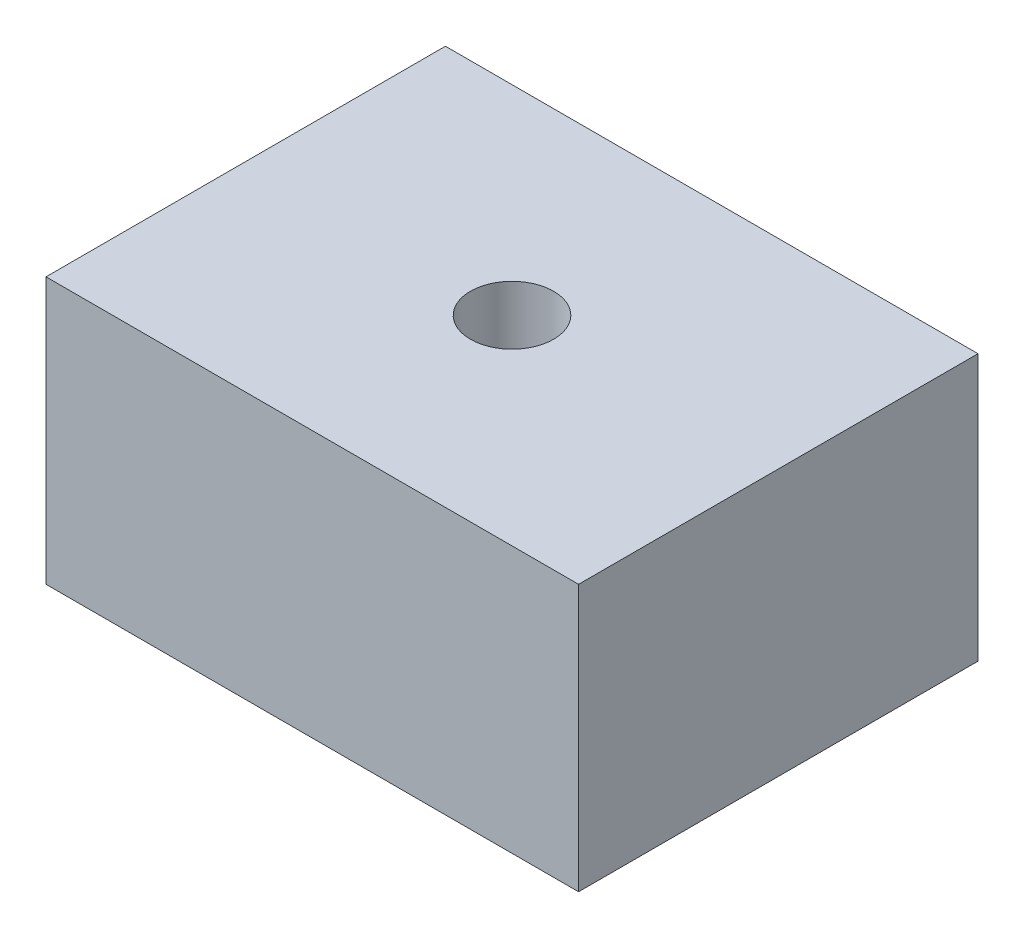
from build123d import *

# Parameters (mm, degrees)
SKETCH1_W               = 50.8
SKETCH1_H               = 38.1
BOSS_EXTRUDE1_DEPTH     = 25.4
F_3_8_16_TAPPED_HOLE1_D = 7.9375


with BuildPart() as part:
    # Sketch1 → Boss-Extrude1 (new body)
    with BuildSketch(Plane(origin=(0, 0, 0), x_dir=(1, 0, 0), z_dir=(0, 1, 0))):
        with Locations((25.4, -19.05)):
            Rectangle(SKETCH1_W, SKETCH1_H)
    extrude(amount=BOSS_EXTRUDE1_DEPTH)

    # 3/8-16 Tapped Hole1 (through all)
    with Locations(Plane(origin=(0, 25.4, 0), x_dir=(1, 0, 0), z_dir=(0, 1, 0))):
        with Locations((25.4, -19.05)):
            Hole(F_3_8_16_TAPPED_HOLE1_D / 2)


solid = part.part
